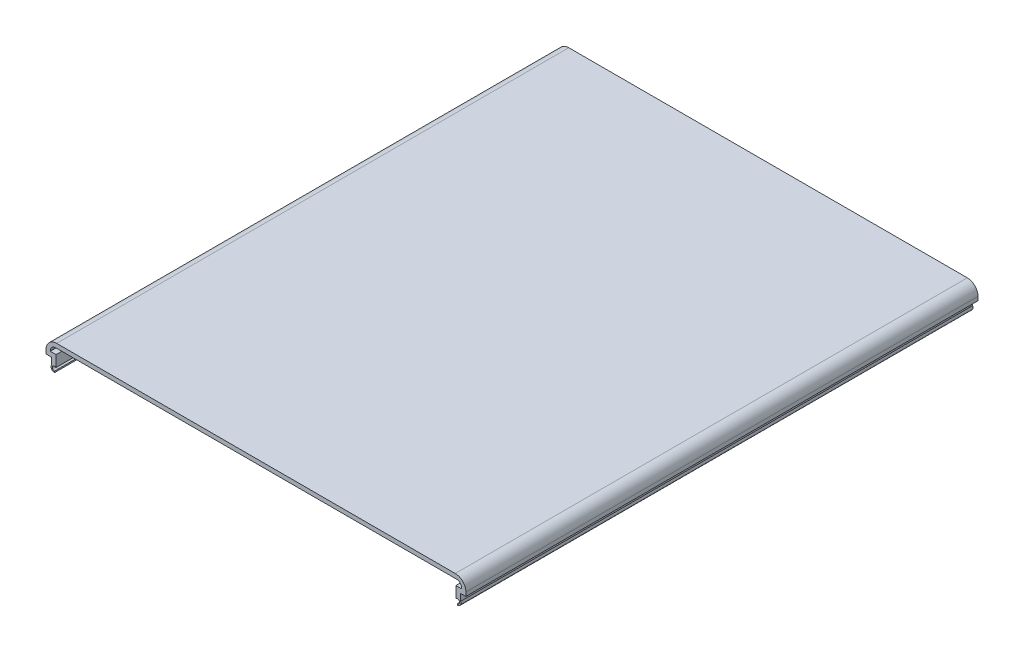
from build123d import *

# Parameters (mm, degrees)
MAINBODY_DEPTH = 304.8


with BuildPart() as part:
    # Sketch2 → MainBody (new body)
    with BuildSketch(Plane.XY):
        with BuildLine():
            Line((-119.888, -15.748740175), (-119.881210728, -14.923222028))
            ThreePointArc((-119.881210728, -14.923222028), (-121.097875098, -13.267102575), (-119.146762684, -12.621994695))
            Line((-119.146762684, -12.621994695), (-118.992266474, -12.621994695))
            Line((-118.992266474, -12.621994695), (-118.992266474, -6.004220787))
            Line((-118.992266474, -6.004220787), (-122.428, -6.004220787))
            Line((-122.428, -6.004220787), (-122.428, -5.715))
            ThreePointArc((-122.428, -5.715), (-121.49806403, -3.46993597), (-119.253, -2.54))
            Line((-119.253, -2.54), (119.253, -2.54))
            ThreePointArc((119.253, -2.54), (121.49806403, -3.46993597), (122.428, -5.715))
            Line((122.428, -5.715), (122.428, -6.004220787))
            Line((122.428, -6.004220787), (118.992266474, -6.004220787))
            Line((118.992266474, -6.004220787), (118.992266474, -12.621994695))
            Line((118.992266474, -12.621994695), (119.146762684, -12.621994695))
            ThreePointArc((119.146762684, -12.621994695), (121.097875098, -13.267102575), (119.881210728, -14.923222028))
            Line((119.881210728, -14.923222028), (119.888, -15.748740175))
            ThreePointArc((119.888, -15.748740175), (121.651583177, -14.78500633), (121.793, -12.780259505))
            Line((121.793, -12.780259505), (121.793, -8.665459505))
            Line((121.793, -8.665459505), (124.968, -8.665459505))
            Line((124.968, -8.665459505), (124.968, -6.35))
            ThreePointArc((124.968, -6.35), (123.108128061, -1.859871939), (118.618, 0))
            Line((118.618, 0), (-118.618, 0))
            ThreePointArc((-118.618, 0), (-123.108128061, -1.859871939), (-124.968, -6.35))
            Line((-124.968, -6.35), (-124.968, -8.665459505))
            Line((-124.968, -8.665459505), (-121.793, -8.665459505))
            Line((-121.793, -8.665459505), (-121.793, -12.780259505))
            ThreePointArc((-121.793, -12.780259505), (-121.651583177, -14.78500633), (-119.888, -15.748740175))
        make_face()
    extrude(amount=MAINBODY_DEPTH)


solid = part.part
